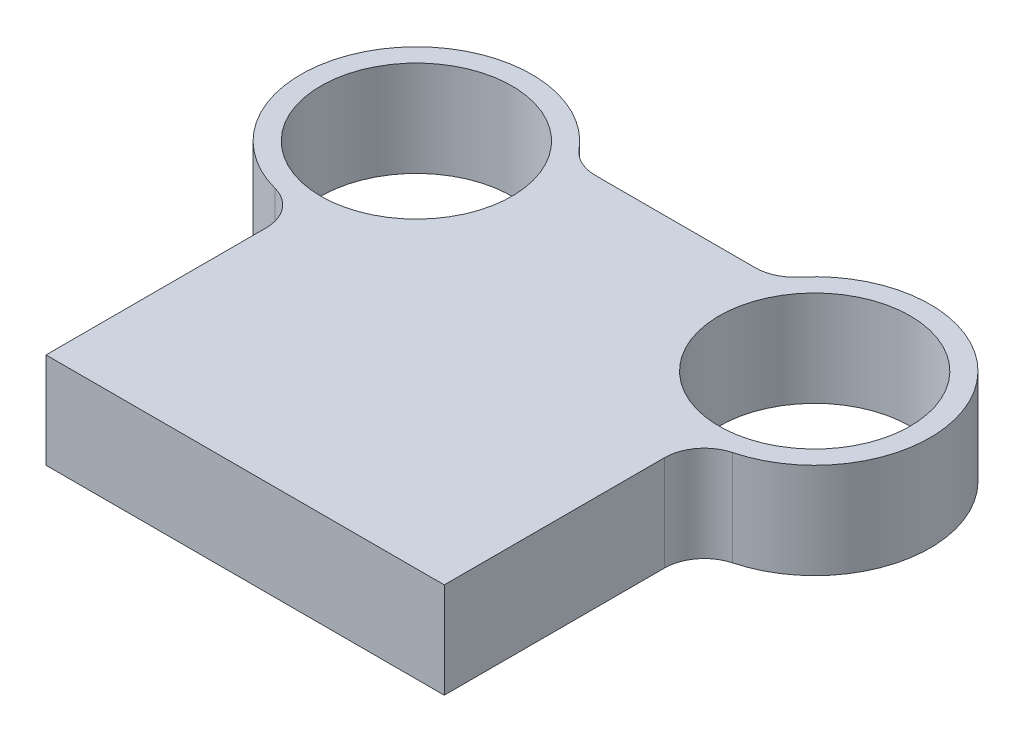
from build123d import *

# Parameters (mm, degrees)
SKETCH1_R           = 24
BOSS_EXTRUDE1_DEPTH = 24
FILLET1_R           = 10


with BuildPart() as part:
    # Sketch1 → Boss-Extrude1 (new body)
    with BuildSketch(Plane(origin=(0, 0, 0), x_dir=(1, 0, 0), z_dir=(0, 1, 0))):
        with BuildLine():
            Line((50, 0), (-50, 0))
            Line((-50, 0), (-50, 64))
            ThreePointArc((-50, 64), (-75.258661881, 107.247806849), (-25.180652708, 108))
            Line((-25.180652708, 108), (25.180652708, 108))
            ThreePointArc((25.180652708, 108), (75.258661881, 107.247806849), (50, 64))
            Line((50, 64), (50, 0))
        make_face()
        with Locations((-50, 93)):
            Circle(SKETCH1_R, mode=Mode.SUBTRACT)
        with Locations((50, 93)):
            Circle(SKETCH1_R, mode=Mode.SUBTRACT)
    extrude(amount=BOSS_EXTRUDE1_DEPTH)

    # Fillet1
    fillet1_edges = [part.edges().sort_by_distance(p)[0] for p in [
        (-50, 12, -64),
        (-25.180652708, 12, -108),
        (25.180652708, 12, -108),
        (50, 12, -64),
    ]]
    fillet(fillet1_edges, radius=FILLET1_R)


solid = part.part
